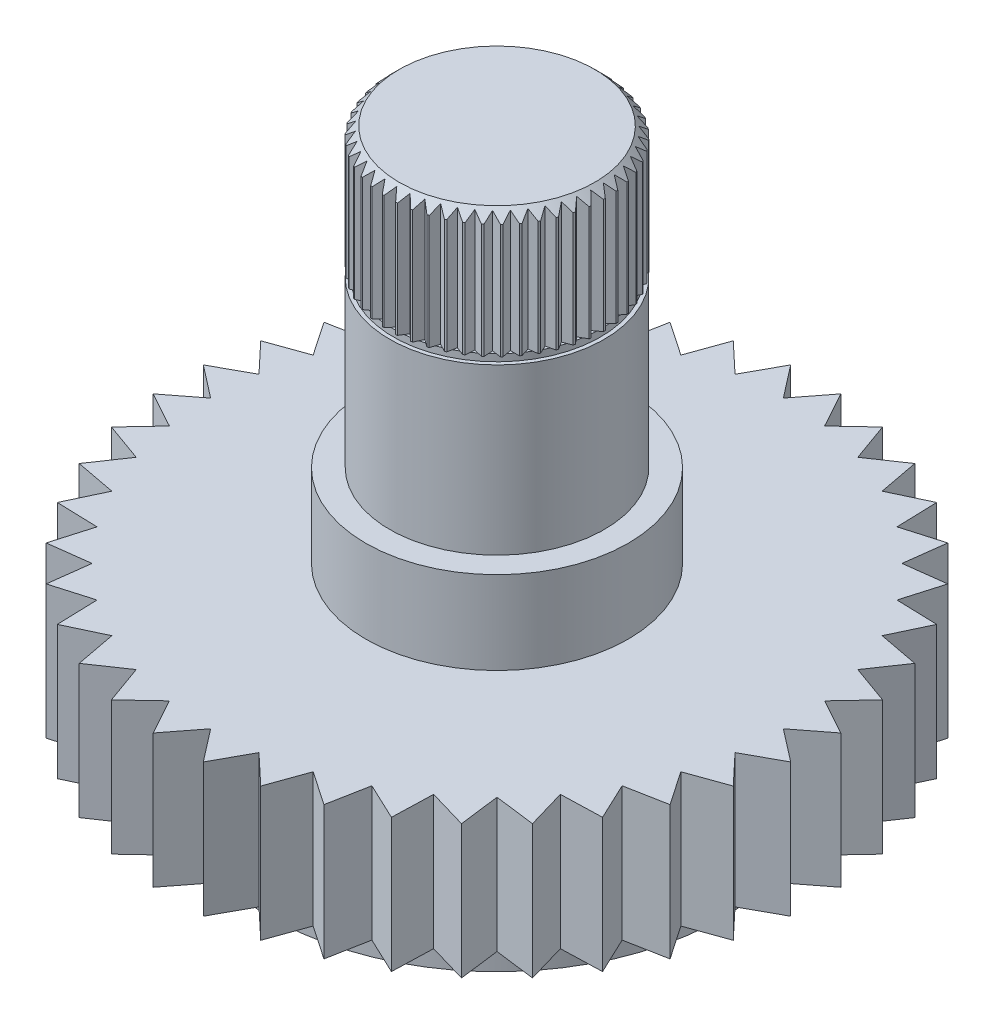
from build123d import *

# Parameters (mm, degrees)
CUT_EXTRUDE1_DEPTH = 2.032
CUT_EXTRUDE2_DEPTH = 6.1562
CIRPATTERN1_COUNT  = 40
CHAMFER1_SIZE      = 0.254
CUT_EXTRUDE3_DEPTH = 3.302
CIRPATTERN2_COUNT  = 50


with BuildPart() as part:
    # Sketch1 → Revolve1 (revolve)
    with BuildSketch(Plane.XY):
        Polygon((6.016, 0), (8.509, 0), (8.509, 3.556), (3.4925, 3.556), (3.4925, 5.7658), (2.8575, 5.7658), (2.8575, 10.150083414), (2.755528071, 10.150083414), (2.755528071, 10.3378), (2.8575, 10.3378), (2.8575, 13.6398), (0, 13.6398), (0, 0.9398), (5, 0.9398), (5, -1.6002), (6.016, -1.6002), align=None)
    revolve(axis=Axis((0, 0, 0), (0, 1, 0)))

    # Sketch2 → Cut-Extrude1 (cut)
    with BuildSketch(Plane.XZ.offset(-0.9398)):
        with BuildLine():
            Line((0, 1.5875), (0, -1.5875))
            ThreePointArc((0, -1.5875), (1.5875, 0), (0, 1.5875))
        make_face()
    extrude(amount=-CUT_EXTRUDE1_DEPTH, mode=Mode.SUBTRACT)

    # Sketch3 → Cut-Extrude2 (cut, through all)
    with BuildSketch(Plane(origin=(0, 3.556, 0), x_dir=(-1, 0, 0), z_dir=(0, 1, 0))):
        with BuildLine():
            Line((0.667608446, -8.482769593), (0, -7.62))
            Line((0, -7.62), (-0.667608446, -8.482769593))
            ThreePointArc((-0.667608446, -8.482769593), (0, -8.509), (0.667608446, -8.482769593))
        make_face()
    cut_extrude2 = extrude(amount=-CUT_EXTRUDE2_DEPTH, mode=Mode.SUBTRACT)

    # CirPattern1: Cut-Extrude2 ×40 about axis
    cirpattern1_axis = Axis((0, 0, 0), (0, 1, 0))
    for i in range(1, CIRPATTERN1_COUNT):
        add(cut_extrude2.rotate(cirpattern1_axis, i * 360 / CIRPATTERN1_COUNT), mode=Mode.SUBTRACT)

    # Chamfer1
    chamfer1_edges = [part.edges().sort_by_distance(p)[0] for p in [
        (-2.8575, 13.6398, 0),
    ]]
    chamfer(chamfer1_edges, length=CHAMFER1_SIZE)

    # Sketch4 → Cut-Extrude3 (cut)
    with BuildSketch(Plane(origin=(0, 13.6398, 0), x_dir=(-1, 0, 0), z_dir=(0, 1, 0))):
        with BuildLine():
            Line((0.155479421, -2.85326697), (0, -2.667))
            Line((0, -2.667), (-0.155479421, -2.85326697))
            ThreePointArc((-0.155479421, -2.85326697), (0, -2.8575), (0.155479421, -2.85326697))
        make_face()
    cut_extrude3 = extrude(amount=-CUT_EXTRUDE3_DEPTH, mode=Mode.SUBTRACT)

    # CirPattern2: Cut-Extrude3 ×50 about axis
    cirpattern2_axis = Axis((0, 0, 0), (0, 1, 0))
    for i in range(1, CIRPATTERN2_COUNT):
        add(cut_extrude3.rotate(cirpattern2_axis, i * 360 / CIRPATTERN2_COUNT), mode=Mode.SUBTRACT)


solid = part.part
